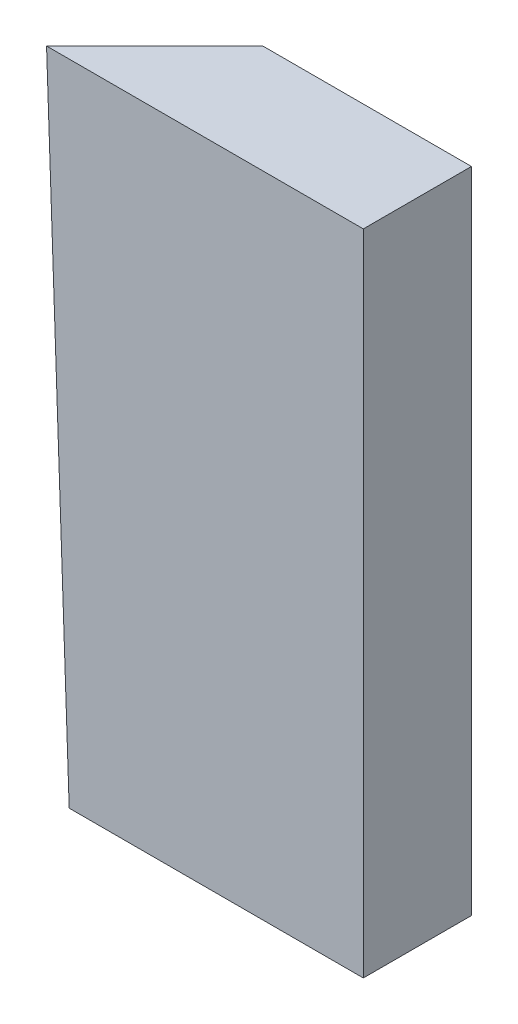
from build123d import *


with BuildPart() as part:
    # Croquis7 → Recubrir3 section 0
    with BuildSketch(Plane(origin=(0, 75, 0), x_dir=(1, 0, 0), z_dir=(0, 1, 0))):
        Polygon((34.000942288, 0), (34.000942288, 12.5), (9.880942288, 12.5), (-2.619057712, 0), align=None)
    # Croquis5 → Recubrir3 section 1
    with BuildSketch(Plane(origin=(0, 0, 0), x_dir=(1, 0, 0), z_dir=(0, 1, 0))):
        Polygon((0, 0), (34, 0), (34, 12.5), (12.5, 12.5), align=None)
    loft()


solid = part.part
